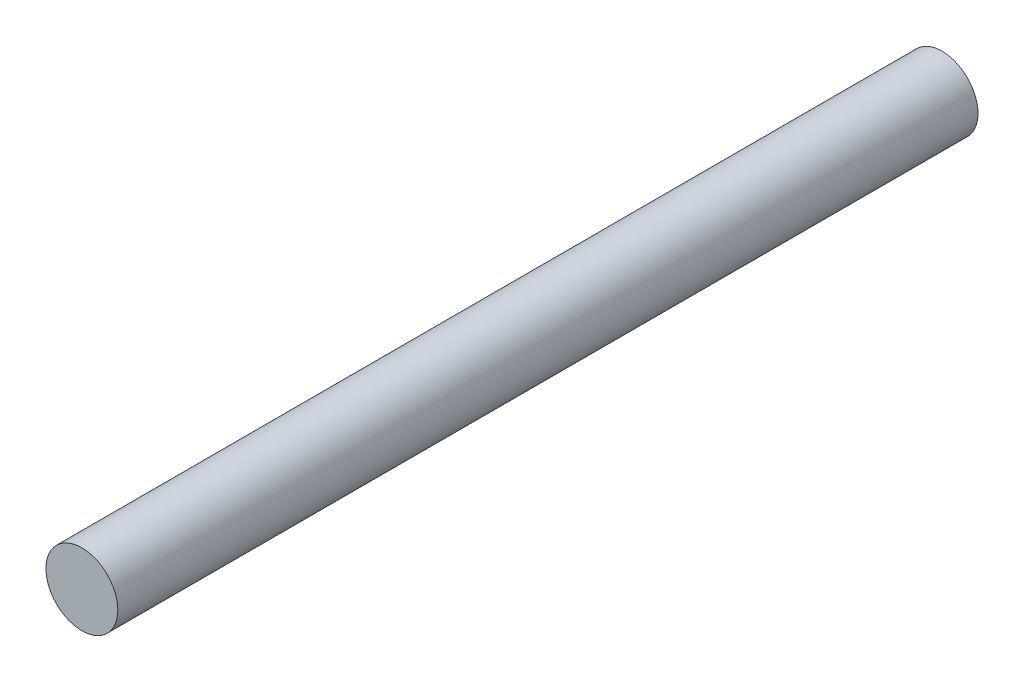
from build123d import *

# Parameters (mm, degrees)
SKETCH1_R           = 31.75
BOSS_EXTRUDE1_DEPTH = 760


with BuildPart() as part:
    # Sketch1 → Boss-Extrude1 (new body)
    with BuildSketch(Plane.XY):
        Circle(SKETCH1_R)
    extrude(amount=BOSS_EXTRUDE1_DEPTH)


solid = part.part
